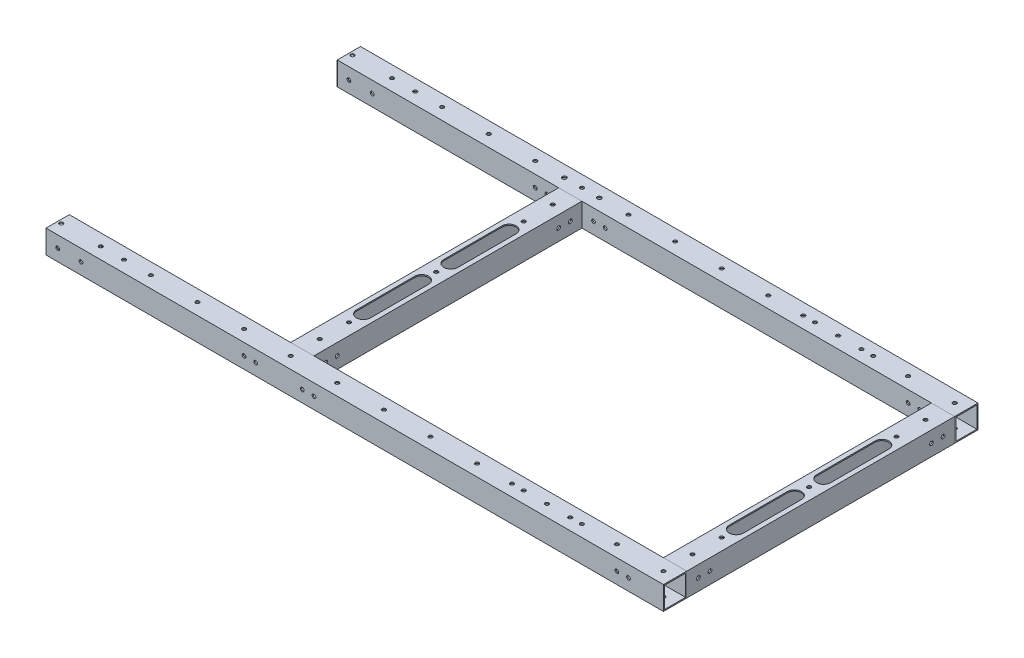
from build123d import *

# Parameters (mm, degrees)
SKETCH_12_W                = 20
SKETCH_12_H                = 20
SKETCH_12_W_2              = 18
SKETCH_12_H_2              = 18
F_20X20X1_2_DEPTH          = 580
SKETCH_12_ON_SEGMENT_2_W   = 20
SKETCH_12_ON_SEGMENT_2_H   = 20
SKETCH_12_ON_SEGMENT_2_W_2 = 18
SKETCH_12_ON_SEGMENT_2_H_2 = 18
F_20X20X1_2_2_DEPTH        = 580
SKETCH_12_ON_SEGMENT_3_W   = 20
SKETCH_12_ON_SEGMENT_3_H   = 20
SKETCH_12_ON_SEGMENT_3_W_2 = 18
SKETCH_12_ON_SEGMENT_3_H_2 = 18
F_20X20X1_2_3_DEPTH        = 252
SKETCH_12_ON_SEGMENT_4_W   = 20
SKETCH_12_ON_SEGMENT_4_H   = 20
SKETCH_12_ON_SEGMENT_4_W_2 = 18
SKETCH_12_ON_SEGMENT_4_H_2 = 18
F_20X20X1_2_4_DEPTH        = 252
SKETCH_13_R                = 1.6
CUT_EXTRUDE_1_DEPTH        = 326.038459263
SKETCH_14_R                = 1.6
CUT_EXTRUDE_2_DEPTH        = 326.038459263
CUT_EXTRUDE_2_DEPTH_BACK   = 326.038459263
SKETCH_15_R                = 1.6
CUT_EXTRUDE_3_DEPTH        = 401.031248779
SKETCH_17_R                = 1.6
CUT_EXTRUDE_5_DEPTH        = 326.038459263
SKETCH_18_R                = 1.6
CUT_EXTRUDE_6_DEPTH        = 326.038459263
SKETCH_20_R                = 1.6
CUT_EXTRUDE_7_DEPTH        = 326.038459263
SKETCH_21_R                = 1.6
CUT_EXTRUDE_8_DEPTH        = 401.031248779
SKETCH_22_R                = 1.6
CUT_EXTRUDE_9_DEPTH        = 326.038459263
SKETCH_23_R                = 1.6
CUT_EXTRUDE_10_DEPTH       = 326.038459263
SKETCH_111_R               = 1.6
CUT_EXTRUDE_11_DEPTH       = 596.587944807
SKETCH_112_W               = 50
SKETCH_112_H               = 270
CUT_EXTRUDE_12_DEPTH       = 20
CUT_EXTRUDE_13_DEPTH       = 20
SKETCH_114_R               = 1.75
CUT_EXTRUDE_14_DEPTH       = 326.038459263


with BuildPart() as part:
    # 草图12 → 铝方管 20X20X1(2) (new body)
    with BuildSketch(Plane(origin=(-285, 0, 125), x_dir=(0, 0, -1), z_dir=(1, 0, 0))):
        Rectangle(SKETCH_12_W, SKETCH_12_H)
        Rectangle(SKETCH_12_W_2, SKETCH_12_H_2, mode=Mode.SUBTRACT)
    extrude(amount=F_20X20X1_2_DEPTH)


with BuildPart() as body_2:
    # 草图12 on segment 2 (carried to segment 2) → 20X20X1_2 2 (new body)
    with BuildSketch(Plane(origin=(-285, 0, -125), x_dir=(0, 0, -1), z_dir=(1, 0, 0))):
        Rectangle(SKETCH_12_ON_SEGMENT_2_W, SKETCH_12_ON_SEGMENT_2_H)
        Rectangle(SKETCH_12_ON_SEGMENT_2_W_2, SKETCH_12_ON_SEGMENT_2_H_2, mode=Mode.SUBTRACT)
    extrude(amount=F_20X20X1_2_2_DEPTH)


with BuildPart() as body_3:
    # 草图12 on segment 3 (carried to segment 3) → 20X20X1_2 3 (new body)
    with BuildSketch(Plane(origin=(285, 0, -126), x_dir=(1, 0, 0), z_dir=(0, 0, 1))):
        Rectangle(SKETCH_12_ON_SEGMENT_3_W, SKETCH_12_ON_SEGMENT_3_H)
        Rectangle(SKETCH_12_ON_SEGMENT_3_W_2, SKETCH_12_ON_SEGMENT_3_H_2, mode=Mode.SUBTRACT)
    extrude(amount=F_20X20X1_2_3_DEPTH)

    # 20X20X1_2 3 end butt 1
    split(bisect_by=Plane(origin=(285, 0, -115), x_dir=(0, -1, 0), z_dir=(0, 0, 1)), keep=Keep.TOP)

    # 20X20X1_2 3 end butt 2
    split(bisect_by=Plane(origin=(285, 0, 115), x_dir=(0, 1, 0), z_dir=(0, 0, -1)), keep=Keep.TOP)


with BuildPart() as body_4:
    # 草图12 on segment 4 (carried to segment 4) → 20X20X1_2 4 (new body)
    with BuildSketch(Plane(origin=(-35, 0, -126), x_dir=(1, 0, 0), z_dir=(0, 0, 1))):
        Rectangle(SKETCH_12_ON_SEGMENT_4_W, SKETCH_12_ON_SEGMENT_4_H)
        Rectangle(SKETCH_12_ON_SEGMENT_4_W_2, SKETCH_12_ON_SEGMENT_4_H_2, mode=Mode.SUBTRACT)
    extrude(amount=F_20X20X1_2_4_DEPTH)

    # 20X20X1_2 4 end butt 1
    split(bisect_by=Plane(origin=(-35, 0, -115), x_dir=(0, -1, 0), z_dir=(0, 0, 1)), keep=Keep.TOP)

    # 20X20X1_2 4 end butt 2
    split(bisect_by=Plane(origin=(-35, 0, 115), x_dir=(0, 1, 0), z_dir=(0, 0, -1)), keep=Keep.TOP)


with BuildPart() as cut_extrude_1_tool:
    # 草图13 → 切除-拉伸1 (new, through all)
    with BuildSketch(Plane(origin=(0, 10, 0), x_dir=(1, 0, 0), z_dir=(0, 1, 0))):
        with Locations(Location((-232, 125, 0), (0, 0, 270))):
            Circle(SKETCH_13_R)
        with Locations(Location((-232, -125, 0), (0, 0, 270))):
            Circle(SKETCH_13_R)
    extrude(amount=-CUT_EXTRUDE_1_DEPTH)


with BuildPart() as part_1:
    add(part.part)

    # 切除-拉伸1: cut by cut_extrude_1_tool
    add(cut_extrude_1_tool.part, mode=Mode.SUBTRACT)


with BuildPart() as body_2_1:
    add(body_2.part)

    # 切除-拉伸1: cut by cut_extrude_1_tool
    add(cut_extrude_1_tool.part, mode=Mode.SUBTRACT)


with BuildPart() as cut_extrude_2_tool:
    # 草图14 → 切除-拉伸2 (new, two sides)
    with BuildSketch(Plane(origin=(0, 10, 0), x_dir=(1, 0, 0), z_dir=(0, 1, 0))) as cut_extrude_2_sk:
        with Locations(Location((185, 125, 0), (0, 0, 270))):
            Circle(SKETCH_14_R)
        with Locations(Location((185, -125, 0), (0, 0, 270))):
            Circle(SKETCH_14_R)
    extrude(amount=CUT_EXTRUDE_2_DEPTH)
    extrude(cut_extrude_2_sk.sketch, amount=-CUT_EXTRUDE_2_DEPTH_BACK)


with BuildPart() as part_2:
    add(part_1.part)

    # 切除-拉伸2: cut by cut_extrude_2_tool
    add(cut_extrude_2_tool.part, mode=Mode.SUBTRACT)


with BuildPart() as body_2_2:
    add(body_2_1.part)

    # 切除-拉伸2: cut by cut_extrude_2_tool
    add(cut_extrude_2_tool.part, mode=Mode.SUBTRACT)


with BuildPart() as cut_extrude_3_tool:
    # 草图15 → 切除-拉伸3 (new, through all)
    with BuildSketch(Plane.XY.offset(135)):
        with Locations((265, 0)):
            Circle(SKETCH_15_R)
        with Locations((255, 0)):
            Circle(SKETCH_15_R)
        with Locations((-15, 0)):
            Circle(SKETCH_15_R)
        with Locations((-5, 0)):
            Circle(SKETCH_15_R)
        with Locations((-55, 0)):
            Circle(SKETCH_15_R)
        with Locations((-65, 0)):
            Circle(SKETCH_15_R)
    extrude(amount=-CUT_EXTRUDE_3_DEPTH)


with BuildPart() as part_3:
    add(part_2.part)

    # 切除-拉伸3: cut by cut_extrude_3_tool
    add(cut_extrude_3_tool.part, mode=Mode.SUBTRACT)


with BuildPart() as body_2_3:
    add(body_2_2.part)

    # 切除-拉伸3: cut by cut_extrude_3_tool
    add(cut_extrude_3_tool.part, mode=Mode.SUBTRACT)


with BuildPart() as cut_extrude_5_tool:
    # 草图17 → 切除-拉伸5 (new, through all)
    with BuildSketch(Plane(origin=(0, 10, 0), x_dir=(1, 0, 0), z_dir=(0, 1, 0))):
        with Locations(Location((245, -125, 0), (0, 0, 270))):
            Circle(SKETCH_17_R)
        with Locations(Location((245, 125, 0), (0, 0, 270))):
            Circle(SKETCH_17_R)
        with Locations(Location((205, 125, 0), (0, 0, 270))):
            Circle(SKETCH_17_R)
        with Locations(Location((205, -125, 0), (0, 0, 270))):
            Circle(SKETCH_17_R)
        with Locations(Location((165, 125, 0), (0, 0, 270))):
            Circle(SKETCH_17_R)
        with Locations(Location((165, -125, 0), (0, 0, 270))):
            Circle(SKETCH_17_R)
        with Locations(Location((125, 125, 0), (0, 0, 270))):
            Circle(SKETCH_17_R)
        with Locations(Location((125, -125, 0), (0, 0, 270))):
            Circle(SKETCH_17_R)
        with Locations(Location((85, 125, 0), (0, 0, 270))):
            Circle(SKETCH_17_R)
        with Locations(Location((85, -125, 0), (0, 0, 270))):
            Circle(SKETCH_17_R)
        with Locations(Location((45, 125, 0), (0, 0, 270))):
            Circle(SKETCH_17_R)
        with Locations(Location((45, -125, 0), (0, 0, 270))):
            Circle(SKETCH_17_R)
        with Locations(Location((5, 125, 0), (0, 0, 270))):
            Circle(SKETCH_17_R)
        with Locations(Location((5, -125, 0), (0, 0, 270))):
            Circle(SKETCH_17_R)
        with Locations(Location((-35, 125, 0), (0, 0, 270))):
            Circle(SKETCH_17_R)
        with Locations(Location((-35, -125, 0), (0, 0, 270))):
            Circle(SKETCH_17_R)
        with Locations(Location((-75, 125, 0), (0, 0, 270))):
            Circle(SKETCH_17_R)
        with Locations(Location((-75, -125, 0), (0, 0, 270))):
            Circle(SKETCH_17_R)
        with Locations(Location((-115, 125, 0), (0, 0, 270))):
            Circle(SKETCH_17_R)
        with Locations(Location((-115, -125, 0), (0, 0, 270))):
            Circle(SKETCH_17_R)
        with Locations(Location((-155, 125, 0), (0, 0, 270))):
            Circle(SKETCH_17_R)
        with Locations(Location((-155, -125, 0), (0, 0, 270))):
            Circle(SKETCH_17_R)
    extrude(amount=-CUT_EXTRUDE_5_DEPTH)


with BuildPart() as part_4:
    add(part_3.part)

    # 切除-拉伸5: cut by cut_extrude_5_tool
    add(cut_extrude_5_tool.part, mode=Mode.SUBTRACT)


with BuildPart() as body_2_4:
    add(body_2_3.part)

    # 切除-拉伸5: cut by cut_extrude_5_tool
    add(cut_extrude_5_tool.part, mode=Mode.SUBTRACT)


with BuildPart() as cut_extrude_6_tool:
    # 草图18 → 切除-拉伸6 (new, through all)
    with BuildSketch(Plane(origin=(0, 10, 0), x_dir=(1, 0, 0), z_dir=(0, 1, 0))):
        with Locations(Location((285, -125, 0), (0, 0, 270))):
            Circle(SKETCH_18_R)
        with Locations(Location((285, -75, 0), (0, 0, 270))):
            Circle(SKETCH_18_R)
        with Locations(Location((285, 0, 0), (0, 0, 270))):
            Circle(SKETCH_18_R)
        with Locations(Location((-35, 0, 0), (0, 0, 270))):
            Circle(SKETCH_18_R)
        with Locations(Location((-35, -75, 0), (0, 0, 270))):
            Circle(SKETCH_18_R)
        with Locations(Location((-35, 75, 0), (0, 0, 270))):
            Circle(SKETCH_18_R)
        with Locations(Location((285, 75, 0), (0, 0, 270))):
            Circle(SKETCH_18_R)
        with Locations(Location((285, 125, 0), (0, 0, 270))):
            Circle(SKETCH_18_R)
        with Locations(Location((285, -100, 0), (0, 0, 270))):
            Circle(SKETCH_18_R)
        with Locations(Location((285, 100, 0), (0, 0, 270))):
            Circle(SKETCH_18_R)
        with Locations(Location((-35, -100, 0), (0, 0, 270))):
            Circle(SKETCH_18_R)
        with Locations(Location((-35, 100, 0), (0, 0, 270))):
            Circle(SKETCH_18_R)
    extrude(amount=-CUT_EXTRUDE_6_DEPTH)


with BuildPart() as part_5:
    add(part_4.part)

    # 切除-拉伸6: cut by cut_extrude_6_tool
    add(cut_extrude_6_tool.part, mode=Mode.SUBTRACT)


with BuildPart() as body_2_5:
    add(body_2_4.part)

    # 切除-拉伸6: cut by cut_extrude_6_tool
    add(cut_extrude_6_tool.part, mode=Mode.SUBTRACT)


with BuildPart() as body_3_1:
    add(body_3.part)

    # 切除-拉伸6: cut by cut_extrude_6_tool
    add(cut_extrude_6_tool.part, mode=Mode.SUBTRACT)


with BuildPart() as body_4_1:
    add(body_4.part)

    # 切除-拉伸6: cut by cut_extrude_6_tool
    add(cut_extrude_6_tool.part, mode=Mode.SUBTRACT)


with BuildPart() as cut_extrude_7_tool:
    # 草图20 → 切除-拉伸7 (new, through all)
    with BuildSketch(Plane(origin=(0, 10, 0), x_dir=(1, 0, 0), z_dir=(0, 1, 0))):
        with Locations(Location((-198, -125, 0), (0, 0, 270))):
            Circle(SKETCH_20_R)
        with Locations(Location((-198, 125, 0), (0, 0, 270))):
            Circle(SKETCH_20_R)
    extrude(amount=-CUT_EXTRUDE_7_DEPTH)


with BuildPart() as part_6:
    add(part_5.part)

    # 切除-拉伸7: cut by cut_extrude_7_tool
    add(cut_extrude_7_tool.part, mode=Mode.SUBTRACT)


with BuildPart() as body_2_6:
    add(body_2_5.part)

    # 切除-拉伸7: cut by cut_extrude_7_tool
    add(cut_extrude_7_tool.part, mode=Mode.SUBTRACT)


with BuildPart() as cut_extrude_8_tool:
    # 草图21 → 切除-拉伸8 (new, through all)
    with BuildSketch(Plane.XY.offset(135)):
        with Locations((-225, 0)):
            Circle(SKETCH_21_R)
        with Locations((-205, 0)):
            Circle(SKETCH_21_R)
    extrude(amount=-CUT_EXTRUDE_8_DEPTH)


with BuildPart() as part_7:
    add(part_6.part)

    # 切除-拉伸8: cut by cut_extrude_8_tool
    add(cut_extrude_8_tool.part, mode=Mode.SUBTRACT)


with BuildPart() as body_2_7:
    add(body_2_6.part)

    # 切除-拉伸8: cut by cut_extrude_8_tool
    add(cut_extrude_8_tool.part, mode=Mode.SUBTRACT)


with BuildPart() as cut_extrude_9_tool:
    # 草图22 → 切除-拉伸9 (new, through all)
    with BuildSketch(Plane(origin=(0, 10, 0), x_dir=(1, 0, 0), z_dir=(0, 1, 0))):
        with Locations(Location((-265, -125, 0), (0, 0, 270))):
            Circle(SKETCH_22_R)
        with Locations(Location((-178, -125, 0), (0, 0, 270))):
            Circle(SKETCH_22_R)
        with Locations(Location((-178, 125, 0), (0, 0, 270))):
            Circle(SKETCH_22_R)
        with Locations(Location((-265, 125, 0), (0, 0, 270))):
            Circle(SKETCH_22_R)
    extrude(amount=-CUT_EXTRUDE_9_DEPTH)


with BuildPart() as part_8:
    add(part_7.part)

    # 切除-拉伸9: cut by cut_extrude_9_tool
    add(cut_extrude_9_tool.part, mode=Mode.SUBTRACT)


with BuildPart() as body_2_8:
    add(body_2_7.part)

    # 切除-拉伸9: cut by cut_extrude_9_tool
    add(cut_extrude_9_tool.part, mode=Mode.SUBTRACT)


with BuildPart() as cut_extrude_10_tool:
    # 草图23 → 切除-拉伸10 (new, through all)
    with BuildSketch(Plane(origin=(0, 10, 0), x_dir=(1, 0, 0), z_dir=(0, 1, 0))):
        with Locations(Location((155, -125, 0), (0, 0, 270))):
            Circle(SKETCH_23_R)
        with Locations(Location((215, -125, 0), (0, 0, 270))):
            Circle(SKETCH_23_R)
        with Locations(Location((215, 125, 0), (0, 0, 270))):
            Circle(SKETCH_23_R)
        with Locations(Location((155, 125, 0), (0, 0, 270))):
            Circle(SKETCH_23_R)
    extrude(amount=-CUT_EXTRUDE_10_DEPTH)


with BuildPart() as part_9:
    add(part_8.part)

    # 切除-拉伸10: cut by cut_extrude_10_tool
    add(cut_extrude_10_tool.part, mode=Mode.SUBTRACT)


with BuildPart() as body_2_9:
    add(body_2_8.part)

    # 切除-拉伸10: cut by cut_extrude_10_tool
    add(cut_extrude_10_tool.part, mode=Mode.SUBTRACT)


with BuildPart() as cut_extrude_11_tool:
    # 草图111 → 切除-拉伸11 (new, through all)
    with BuildSketch(Plane(origin=(295, 0, 0), x_dir=(0, 0, -1), z_dir=(1, 0, 0))):
        with Locations((105, 0)):
            Circle(SKETCH_111_R)
        with Locations((95, 0)):
            Circle(SKETCH_111_R)
        with Locations(Location((-95, 0, 0), (0, 0, 180))):
            Circle(SKETCH_111_R)
        with Locations(Location((-105, 0, 0), (0, 0, 180))):
            Circle(SKETCH_111_R)
    extrude(amount=-CUT_EXTRUDE_11_DEPTH)


with BuildPart() as body_3_2:
    add(body_3_1.part)

    # 切除-拉伸11: cut by cut_extrude_11_tool
    add(cut_extrude_11_tool.part, mode=Mode.SUBTRACT)


with BuildPart() as body_4_2:
    add(body_4_1.part)

    # 切除-拉伸11: cut by cut_extrude_11_tool
    add(cut_extrude_11_tool.part, mode=Mode.SUBTRACT)


with BuildPart() as cut_extrude_12_tool:
    # 草图112 → 切除-拉伸12 (new body)
    with BuildSketch(Plane(origin=(0, 10, 0), x_dir=(1, 0, 0), z_dir=(0, 1, 0))):
        with Locations((-260, 0)):
            Rectangle(SKETCH_112_W, SKETCH_112_H)
    extrude(amount=-CUT_EXTRUDE_12_DEPTH)


with BuildPart() as part_10:
    add(part_9.part)

    # 切除-拉伸12: cut by cut_extrude_12_tool
    add(cut_extrude_12_tool.part, mode=Mode.SUBTRACT)


with BuildPart() as body_2_10:
    add(body_2_9.part)

    # 切除-拉伸12: cut by cut_extrude_12_tool
    add(cut_extrude_12_tool.part, mode=Mode.SUBTRACT)

    # 草图114 → 切除-拉伸14 (cut, through all)
    with BuildSketch(Plane(origin=(0, 10, 0), x_dir=(1, 0, 0), z_dir=(0, 1, 0))):
        with Locations(Location((-20, 125, 0), (0, 0, 270))):
            Circle(SKETCH_114_R)
        with Locations(Location((-50, 125, 0), (0, 0, 270))):
            Circle(SKETCH_114_R)
    extrude(amount=-CUT_EXTRUDE_14_DEPTH, mode=Mode.SUBTRACT)


with BuildPart() as cut_extrude_13_tool:
    # 草图113 → 切除-拉伸13 (new body)
    with BuildSketch(Plane(origin=(0, 10, 0), x_dir=(1, 0, 0), z_dir=(0, 1, 0))):
        with BuildLine():
            Line((-29, 62.5), (-29, 12.5))
            ThreePointArc((-29, 12.5), (-35, 6.5), (-41, 12.5))
            Line((-41, 12.5), (-41, 62.5))
            ThreePointArc((-41, 62.5), (-35, 68.5), (-29, 62.5))
        make_face()
        with BuildLine():
            Line((-29, -62.5), (-29, -12.5))
            ThreePointArc((-29, -12.5), (-35, -6.5), (-41, -12.5))
            Line((-41, -12.5), (-41, -62.5))
            ThreePointArc((-41, -62.5), (-35, -68.5), (-29, -62.5))
        make_face()
        with BuildLine():
            Line((279, -62.5), (279, -12.5))
            ThreePointArc((279, -12.5), (285, -6.5), (291, -12.5))
            Line((291, -12.5), (291, -62.5))
            ThreePointArc((291, -62.5), (285, -68.5), (279, -62.5))
        make_face()
        with BuildLine():
            Line((279, 62.5), (279, 12.5))
            ThreePointArc((279, 12.5), (285, 6.5), (291, 12.5))
            Line((291, 12.5), (291, 62.5))
            ThreePointArc((291, 62.5), (285, 68.5), (279, 62.5))
        make_face()
    extrude(amount=-CUT_EXTRUDE_13_DEPTH)


with BuildPart() as body_3_3:
    add(body_3_2.part)

    # 切除-拉伸13: cut by cut_extrude_13_tool
    add(cut_extrude_13_tool.part, mode=Mode.SUBTRACT)


with BuildPart() as body_4_3:
    add(body_4_2.part)

    # 切除-拉伸13: cut by cut_extrude_13_tool
    add(cut_extrude_13_tool.part, mode=Mode.SUBTRACT)


solid = Compound([part_10.part, body_2_10.part, body_3_3.part, body_4_3.part])
